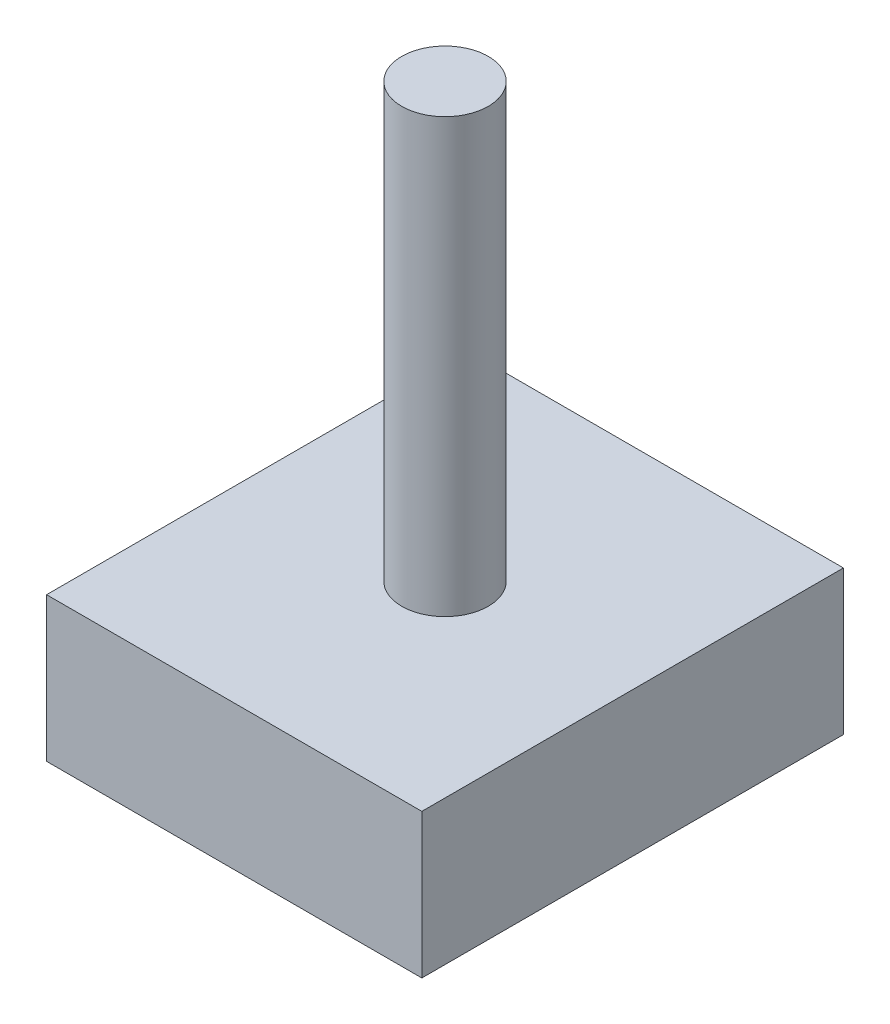
from build123d import *

# Parameters (mm, degrees)
SKETCH_1_W      = 13
SKETCH_1_H      = 14.605053714
EXTRUDE_1_DEPTH = 5
SKETCH_2_R      = 1.5
EXTRUDE_2_DEPTH = 15


with BuildPart() as part:
    # 草图1 → 凸台-拉伸1 (new body)
    with BuildSketch(Plane(origin=(0, 0, 0), x_dir=(1, 0, 0), z_dir=(0, 1, 0))):
        Rectangle(SKETCH_1_W, SKETCH_1_H)
    extrude(amount=EXTRUDE_1_DEPTH)

    # 草图2 → 凸台-拉伸2 (add)
    with BuildSketch(Plane(origin=(0, 5, 0), x_dir=(1, 0, 0), z_dir=(0, 1, 0))):
        Circle(SKETCH_2_R)
    extrude(amount=EXTRUDE_2_DEPTH)


solid = part.part
